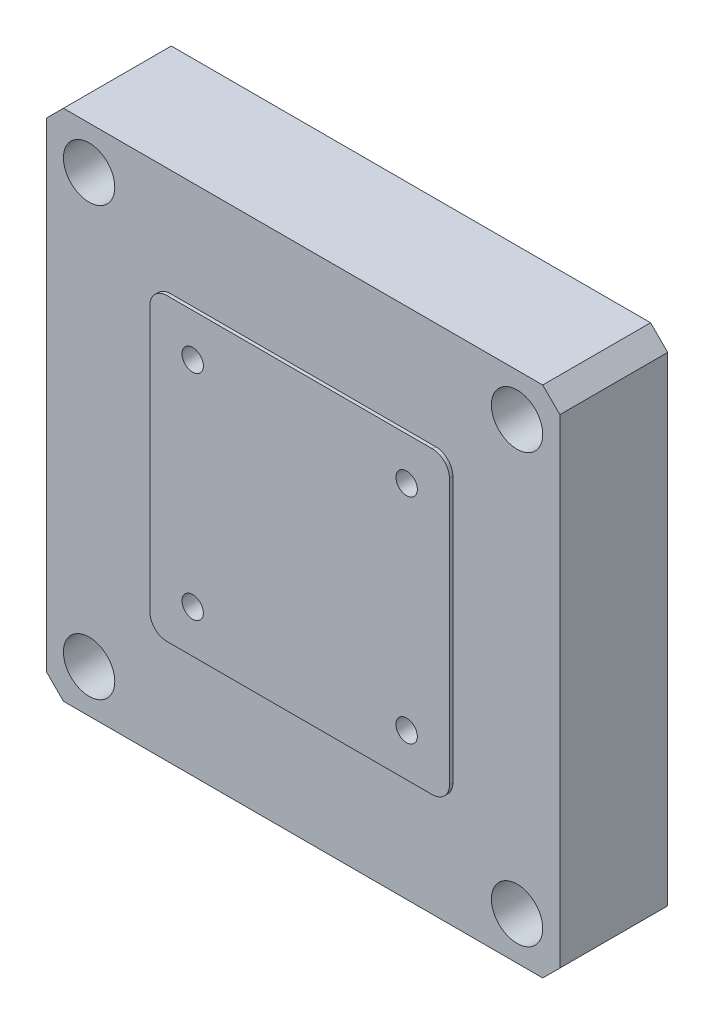
from build123d import *

# Parameters (mm, degrees)
SKETCH_1_W                = 60
SKETCH_1_H                = 60
EXTRUDE_1_DEPTH           = 12.6
CHAMFER_1_SIZE            = 2
SKETCH_2_W                = 35
SKETCH_2_H                = 35
EXTRUDE_2_DEPTH           = 0.4
FILLET_1_R                = 2
HOLE_WIZARD_1_D           = 3.4
HOLE_WIZARD_1_CBORE_D     = 6
HOLE_WIZARD_1_CBORE_DEPTH = 5
HOLE_WIZARD_M3_1_D        = 2.5
HOLE_WIZARD_M3_1_DEPTH    = 3.5
HOLE_WIZARD_M3_1_TIP      = 0.751075774


with BuildPart() as part:
    # 草图1 → 凸台-拉伸1 (new body)
    with BuildSketch(Plane.XY):
        Rectangle(SKETCH_1_W, SKETCH_1_H)
    extrude(amount=EXTRUDE_1_DEPTH)

    # 倒角1
    chamfer_1_edges = [part.edges().sort_by_distance(p)[0] for p in [
        (30, -30, 6.3),
        (-30, -30, 6.3),
        (-30, 30, 6.3),
        (30, 30, 6.3),
    ]]
    chamfer(chamfer_1_edges, length=CHAMFER_1_SIZE)

    # 草图2 → 凸台-拉伸2 (add)
    with BuildSketch(Plane.XY.offset(12.6)):
        Rectangle(SKETCH_2_W, SKETCH_2_H)
    extrude(amount=EXTRUDE_2_DEPTH)

    # 圆角1
    fillet_1_edges = [part.edges().sort_by_distance(p)[0] for p in [
        (17.5, -17.5, 12.8),
        (17.5, 17.5, 12.8),
        (-17.5, 17.5, 12.8),
        (-17.5, -17.5, 12.8),
    ]]
    fillet(fillet_1_edges, radius=FILLET_1_R)

    # 孔1 (through all)
    with Locations(Plane(origin=(-25, 25, 12.6), x_dir=(1, 0, 0), z_dir=(0, 0, 1))):
        with Locations((0, 0), (50, 0), (0, -50), (50, -50)):
            CounterBoreHole(HOLE_WIZARD_1_D / 2, HOLE_WIZARD_1_CBORE_D / 2, HOLE_WIZARD_1_CBORE_DEPTH)

    # M3 螺纹孔1
    with Locations(Plane(origin=(-12.5, 12.5, 13), x_dir=(1, 0, 0), z_dir=(0, 0, 1))):
        with Locations((0, 0), (25, 0), (25, -25), (0, -25)):
            Hole(HOLE_WIZARD_M3_1_D / 2, depth=HOLE_WIZARD_M3_1_DEPTH)
            with Locations((0, 0, -(HOLE_WIZARD_M3_1_DEPTH + HOLE_WIZARD_M3_1_TIP / 2))):  # 118° drill point
                Cone(0, HOLE_WIZARD_M3_1_D / 2, HOLE_WIZARD_M3_1_TIP, mode=Mode.SUBTRACT)


solid = part.part
